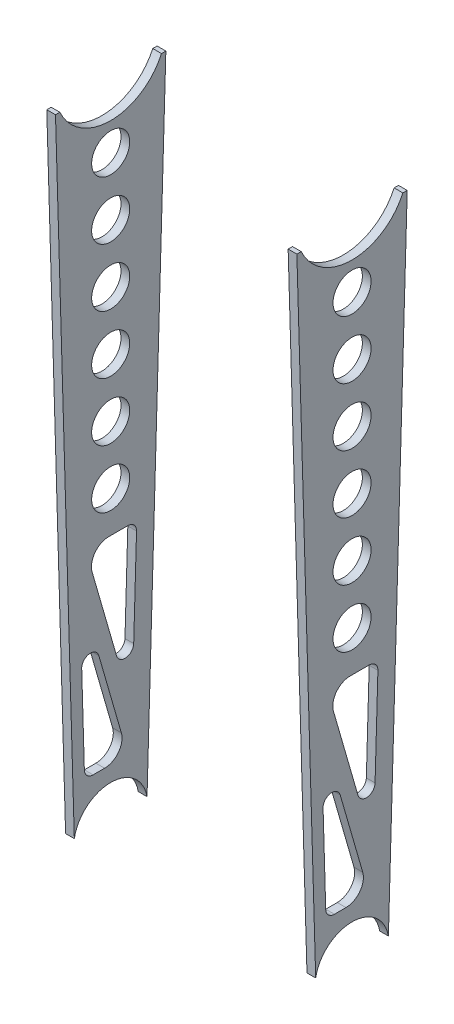
from build123d import *

# Parameters (mm, degrees)
SKETCH1_2_R         = 6.54812
BOSS_EXTRUDE2_DEPTH = 3
BOSS_EXTRUDE1_START = 80
SKETCH1_R           = 6.54812
BOSS_EXTRUDE1_DEPTH = 3


with BuildPart() as part:
    # Sketch1_2 → Boss-Extrude2 (new body)
    with BuildSketch(Plane(origin=(0, 0, 0), x_dir=(0, 0, -1), z_dir=(1, 0, 0))):
        with BuildLine():
            Line((-18.973056002, -7.958160211), (-12.502432925, -226.768594398))
            ThreePointArc((-12.502432925, -226.768594398), (0, -216.3), (12.502432925, -226.768594398))
            Line((12.502432925, -226.768594398), (18.973056002, -7.958160211))
            Line((18.973056002, -7.958160211), (17.473056002, -7.958160211))
            ThreePointArc((17.473056002, -7.958160211), (0, -19.2), (-17.473056002, -7.958160211))
            Line((-17.473056002, -7.958160211), (-18.973056002, -7.958160211))
        make_face()
        with Locations((0, -48.749422679)):
            Circle(SKETCH1_2_R, mode=Mode.SUBTRACT)
        with Locations((0, -28.74812)):
            Circle(SKETCH1_2_R, mode=Mode.SUBTRACT)
        with Locations((0, -68.750725358)):
            Circle(SKETCH1_2_R, mode=Mode.SUBTRACT)
        with Locations((0, -88.752028037)):
            Circle(SKETCH1_2_R, mode=Mode.SUBTRACT)
        with Locations((0, -108.753330716)):
            Circle(SKETCH1_2_R, mode=Mode.SUBTRACT)
        with Locations((0, -128.754633395)):
            Circle(SKETCH1_2_R, mode=Mode.SUBTRACT)
        with BuildLine():
            Line((-4.079756176, -176.464642755), (3.666856963, -203.338094537))
            ThreePointArc((3.666856963, -203.338094537), (2.695952323, -208.607531512), (-2.0983898, -211))
            Line((-2.0983898, -211), (-6.054394391, -211))
            ThreePointArc((-6.054394391, -211), (-8.144127616, -210.152443971), (-9.053083512, -208.088676699))
            Line((-9.053083512, -208.088676699), (-9.961068678, -177.384272185))
            ThreePointArc((-9.961068678, -177.384272185), (-7.425841946, -174.33161124), (-4.079756176, -176.464642755))
        make_face(mode=Mode.SUBTRACT)
        with BuildLine():
            Line((-0.619612161, -142.754633395), (5.894460955, -142.754633395))
            ThreePointArc((5.894460955, -142.754633395), (8.046743318, -143.664831826), (8.892924931, -145.843078193))
            Line((8.892924931, -145.843078193), (7.915908511, -178.881841947))
            ThreePointArc((7.915908511, -178.881841947), (5.292867152, -181.769553791), (2.034596009, -179.624117979))
            Line((2.034596009, -179.624117979), (-6.384858924, -150.416538858))
            ThreePointArc((-6.384858924, -150.416538858), (-5.413954284, -145.147101883), (-0.619612161, -142.754633395))
        make_face(mode=Mode.SUBTRACT)
    extrude(amount=-BOSS_EXTRUDE2_DEPTH)


with BuildPart() as body_2:
    # Sketch1 → Boss-Extrude1 (new body)
    with BuildSketch(Plane(origin=(0, 0, 0), x_dir=(0, 0, -1), z_dir=(1, 0, 0)).offset(BOSS_EXTRUDE1_START)):
        with BuildLine():
            Line((-18.973056002, -7.958160211), (-12.502432925, -226.768594398))
            ThreePointArc((-12.502432925, -226.768594398), (0, -216.3), (12.502432925, -226.768594398))
            Line((12.502432925, -226.768594398), (18.973056002, -7.958160211))
            Line((18.973056002, -7.958160211), (17.473056002, -7.958160211))
            ThreePointArc((17.473056002, -7.958160211), (0, -19.2), (-17.473056002, -7.958160211))
            Line((-17.473056002, -7.958160211), (-18.973056002, -7.958160211))
        make_face()
        with Locations((0, -48.749422679)):
            Circle(SKETCH1_R, mode=Mode.SUBTRACT)
        with Locations((0, -28.74812)):
            Circle(SKETCH1_R, mode=Mode.SUBTRACT)
        with Locations((0, -68.750725358)):
            Circle(SKETCH1_R, mode=Mode.SUBTRACT)
        with Locations((0, -88.752028037)):
            Circle(SKETCH1_R, mode=Mode.SUBTRACT)
        with Locations((0, -108.753330716)):
            Circle(SKETCH1_R, mode=Mode.SUBTRACT)
        with Locations((0, -128.754633395)):
            Circle(SKETCH1_R, mode=Mode.SUBTRACT)
        with BuildLine():
            Line((-4.079756176, -176.464642755), (3.666856963, -203.338094537))
            ThreePointArc((3.666856963, -203.338094537), (2.695952323, -208.607531512), (-2.0983898, -211))
            Line((-2.0983898, -211), (-6.054394391, -211))
            ThreePointArc((-6.054394391, -211), (-8.144127616, -210.152443971), (-9.053083512, -208.088676699))
            Line((-9.053083512, -208.088676699), (-9.961068678, -177.384272185))
            ThreePointArc((-9.961068678, -177.384272185), (-7.425841946, -174.33161124), (-4.079756176, -176.464642755))
        make_face(mode=Mode.SUBTRACT)
        with BuildLine():
            Line((-0.619612161, -142.754633395), (5.894460955, -142.754633395))
            ThreePointArc((5.894460955, -142.754633395), (8.046743318, -143.664831826), (8.892924931, -145.843078193))
            Line((8.892924931, -145.843078193), (7.915908511, -178.881841947))
            ThreePointArc((7.915908511, -178.881841947), (5.292867152, -181.769553791), (2.034596009, -179.624117979))
            Line((2.034596009, -179.624117979), (-6.384858924, -150.416538858))
            ThreePointArc((-6.384858924, -150.416538858), (-5.413954284, -145.147101883), (-0.619612161, -142.754633395))
        make_face(mode=Mode.SUBTRACT)
    extrude(amount=BOSS_EXTRUDE1_DEPTH)


solid = Compound([part.part, body_2.part])
